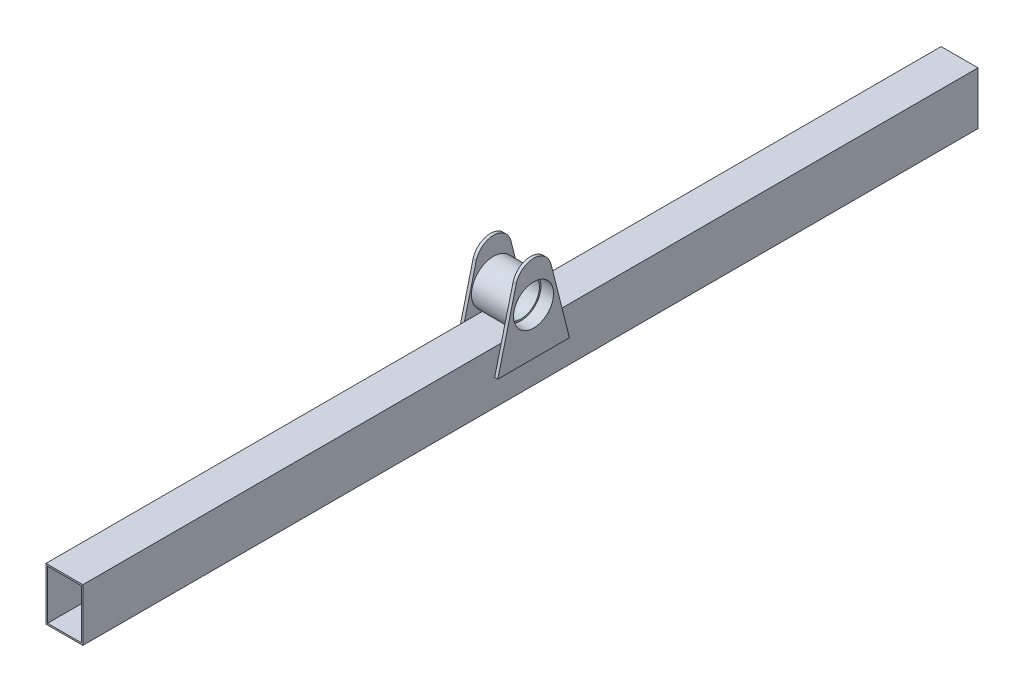
from build123d import *

# Parameters (mm, degrees)
SKETCH1_W           = 35
SKETCH1_H           = 50
SKETCH1_W_2         = 32
SKETCH1_H_2         = 47
BOSS_EXTRUDE1_DEPTH = 460
BOSS_EXTRUDE2_DEPTH = 3
SKETCH3_R           = 19
CUT_EXTRUDE1_DEPTH  = 3
SKETCH5_R           = 21
SKETCH5_R_2         = 17.5
BOSS_EXTRUDE7_DEPTH = 35
SKETCH6_R           = 19
CUT_EXTRUDE2_DEPTH  = 9
SKETCH1_2_W         = 35
SKETCH1_2_H         = 50
SKETCH1_2_W_2       = 32
SKETCH1_2_H_2       = 47
BOSS_EXTRUDE8_DEPTH = 390


with BuildPart() as part:
    # Sketch1 → Boss-Extrude1 (new body)
    with BuildSketch(Plane.XY):
        Rectangle(SKETCH1_W, SKETCH1_H)
        Rectangle(SKETCH1_W_2, SKETCH1_H_2, mode=Mode.SUBTRACT)
    extrude(amount=BOSS_EXTRUDE1_DEPTH)

    # Sketch2 → Boss-Extrude2 (add)
    with BuildSketch(Plane.ZY.offset(17.5)):
        with BuildLine():
            Line((1, 0), (7.296110466, 25))
            Line((7.296110466, 25), (18.5, 69.487344987))
            ThreePointArc((18.5, 69.487344987), (35, 82.347129464), (51.5, 69.487344987))
            Line((51.5, 69.487344987), (62.703889534, 25))
            Line((62.703889534, 25), (69, 0))
            Line((69, 0), (1, 0))
        make_face()
    boss_extrude2 = extrude(amount=BOSS_EXTRUDE2_DEPTH)

    # Sketch3 → Cut-Extrude1 (cut)
    with BuildSketch(Plane.ZY.offset(20.5)):
        with Locations(Location((35, 44, 0), (0, 0, 270))):
            Circle(SKETCH3_R)
    cut_extrude1 = extrude(amount=-CUT_EXTRUDE1_DEPTH, mode=Mode.SUBTRACT)

    # Mirror1: Boss-Extrude2, Cut-Extrude1 across plane
    add(boss_extrude2.mirror(Plane(origin=(0, 0, 0), x_dir=(0, 0, 1), z_dir=(1, 0, 0))))
    add(cut_extrude1.mirror(Plane(origin=(0, 0, 0), x_dir=(0, 0, 1), z_dir=(1, 0, 0))), mode=Mode.SUBTRACT)

    # Sketch5 → Boss-Extrude7 (add)
    with BuildSketch(Plane(origin=(-17.5, 0, 0), x_dir=(0, 0, -1), z_dir=(1, 0, 0))):
        with Locations((-35, 44)):
            Circle(SKETCH5_R)
        with Locations(Location((-35, 44, 0), (0, 0, 270))):
            Circle(SKETCH5_R_2, mode=Mode.SUBTRACT)
    extrude(amount=BOSS_EXTRUDE7_DEPTH)

    # Sketch6 → Cut-Extrude2 (cut)
    with BuildSketch(Plane(origin=(17.5, 0, 0), x_dir=(0, 0, -1), z_dir=(1, 0, 0))):
        with Locations(Location((-35, 44, 0), (0, 0, 270))):
            Circle(SKETCH6_R)
    cut_extrude2 = extrude(amount=-CUT_EXTRUDE2_DEPTH, mode=Mode.SUBTRACT)

    # Mirror2: Cut-Extrude2 across plane
    add(cut_extrude2.mirror(Plane(origin=(0, 0, 0), x_dir=(0, 0, 1), z_dir=(1, 0, 0))), mode=Mode.SUBTRACT)

    # Sketch1_2 → Boss-Extrude8 (add)
    with BuildSketch(Plane.XY):
        Rectangle(SKETCH1_2_W, SKETCH1_2_H)
        Rectangle(SKETCH1_2_W_2, SKETCH1_2_H_2, mode=Mode.SUBTRACT)
    extrude(amount=-BOSS_EXTRUDE8_DEPTH)


solid = part.part
